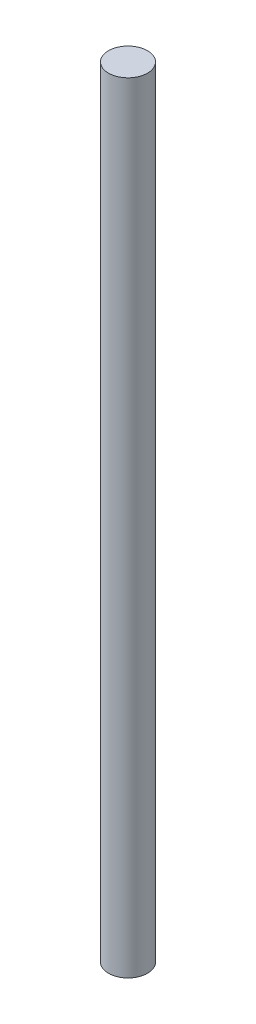
from build123d import *

# Parameters (mm, degrees)
SKETCH1_R      = 12.7
EXTRUDE1_DEPTH = 508


with BuildPart() as part:
    # Sketch1 → Extrude1 (new body)
    with BuildSketch(Plane(origin=(0, 0, 0), x_dir=(1, 0, 0), z_dir=(0, 1, 0))):
        Circle(SKETCH1_R)
    extrude(amount=EXTRUDE1_DEPTH)


solid = part.part
